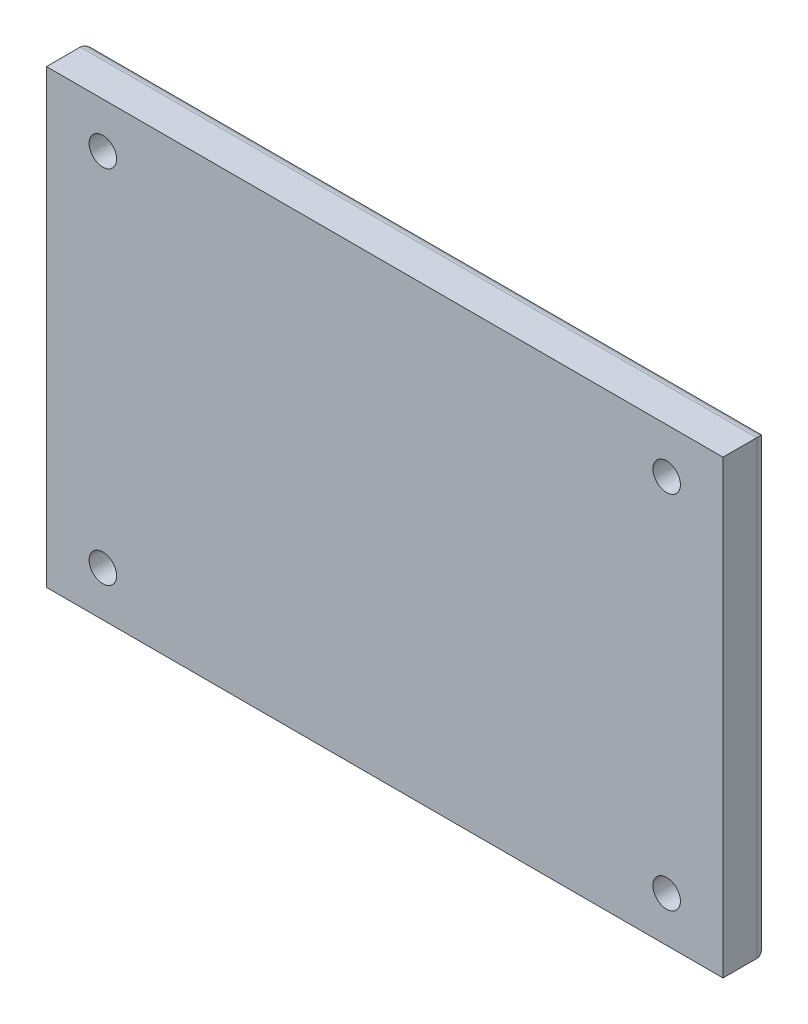
from build123d import *

# Parameters (mm, degrees)
SKETCH1_W                                      = 60
SKETCH1_H                                      = 40
BOSS_EXTRUDE1_DEPTH                            = 4
FILLET1_R                                      = 1
CBORE_FOR_2_SOCKET_HEAD_CAP_SCREW1_D           = 2.4384
CBORE_FOR_2_SOCKET_HEAD_CAP_SCREW1_DEPTH       = 15
CBORE_FOR_2_SOCKET_HEAD_CAP_SCREW1_CBORE_D     = 4.7625
CBORE_FOR_2_SOCKET_HEAD_CAP_SCREW1_CBORE_DEPTH = 2.1844
CBORE_FOR_2_SOCKET_HEAD_CAP_SCREW1_TIP         = 0.732569267


with BuildPart() as part:
    # Sketch1 → Boss-Extrude1 (new body)
    with BuildSketch(Plane.XY):
        Rectangle(SKETCH1_W, SKETCH1_H)
    extrude(amount=BOSS_EXTRUDE1_DEPTH)

    # Fillet1
    fillet1_edges = [part.edges().sort_by_distance(p)[0] for p in [
        (0, -20, 0),
        (-30, 0, 0),
        (0, 20, 0),
        (30, 0, 0),
    ]]
    fillet(fillet1_edges, radius=FILLET1_R)

    # CBORE for #2 Socket Head Cap Screw1
    with Locations(Plane(origin=(-25, -16, 0), x_dir=(-1, 0, 0), z_dir=(0, 0, -1))):
        with Locations((0, 0), (0, 32), (-50, 32), (-50, 0)):
            CounterBoreHole(CBORE_FOR_2_SOCKET_HEAD_CAP_SCREW1_D / 2, CBORE_FOR_2_SOCKET_HEAD_CAP_SCREW1_CBORE_D / 2, CBORE_FOR_2_SOCKET_HEAD_CAP_SCREW1_CBORE_DEPTH, depth=CBORE_FOR_2_SOCKET_HEAD_CAP_SCREW1_DEPTH)
            with Locations((0, 0, -(CBORE_FOR_2_SOCKET_HEAD_CAP_SCREW1_DEPTH + CBORE_FOR_2_SOCKET_HEAD_CAP_SCREW1_TIP / 2))):  # 118° drill point
                Cone(0, CBORE_FOR_2_SOCKET_HEAD_CAP_SCREW1_D / 2, CBORE_FOR_2_SOCKET_HEAD_CAP_SCREW1_TIP, mode=Mode.SUBTRACT)


solid = part.part
